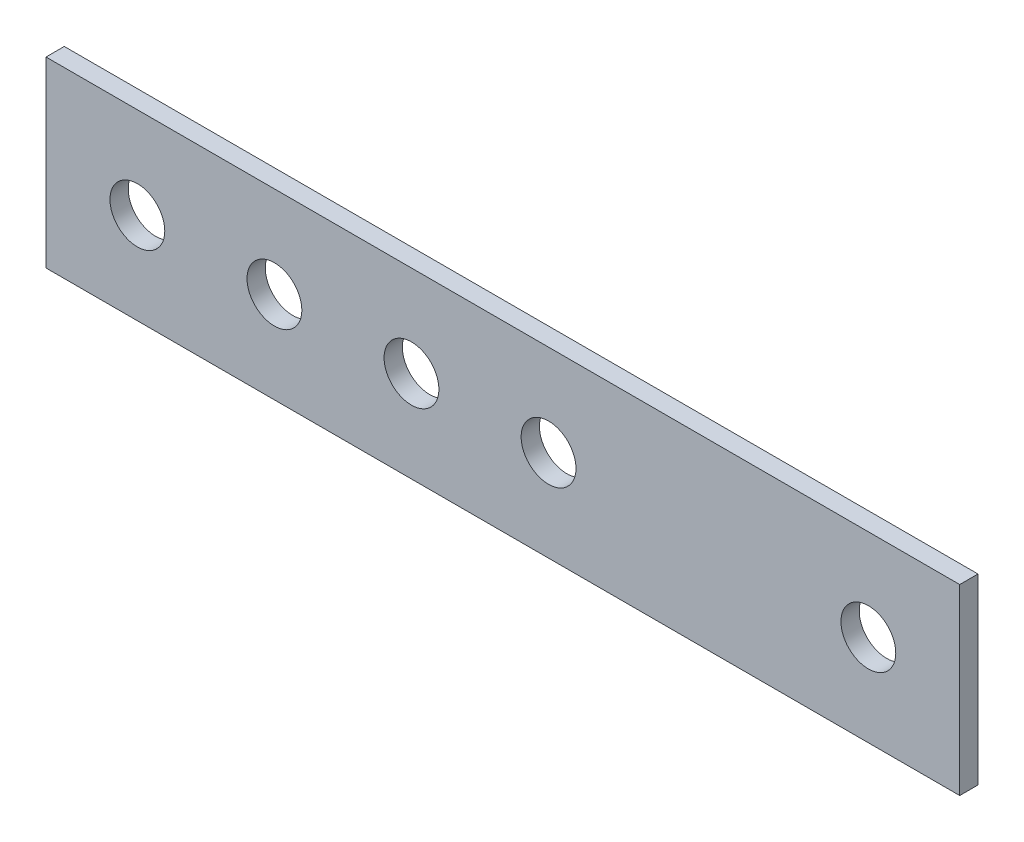
from build123d import *

# Parameters (mm, degrees)
SKETCH1_W           = 200
SKETCH1_H           = 40
SKETCH1_R           = 6
BOSS_EXTRUDE1_DEPTH = 2
SKETCH2_R           = 6
CUT_EXTRUDE1_DEPTH  = 5
LPATTERN1_COUNT     = 4
LPATTERN1_PITCH     = 30


with BuildPart() as part:
    # Sketch1 → Boss-Extrude1 (new body, symmetric)
    with BuildSketch(Plane.XY):
        Rectangle(SKETCH1_W, SKETCH1_H)
        with Locations((80, 0)):
            Circle(SKETCH1_R, mode=Mode.SUBTRACT)
    extrude(amount=BOSS_EXTRUDE1_DEPTH, both=True)

    # Sketch2 → Cut-Extrude1 (cut, through all)
    with BuildSketch(Plane.XY.offset(2)):
        with Locations((-80, 0)):
            Circle(SKETCH2_R)
    cut_extrude1 = extrude(amount=-CUT_EXTRUDE1_DEPTH, mode=Mode.SUBTRACT)

    # LPattern1: Cut-Extrude1 ×4
    with Locations(*[(i * LPATTERN1_PITCH, 0, 0) for i in range(1, LPATTERN1_COUNT)]):
        add(cut_extrude1, mode=Mode.SUBTRACT)


solid = part.part
